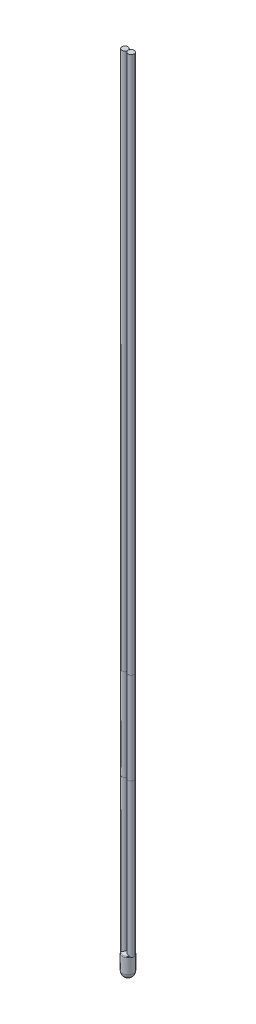
from build123d import *

# Parameters (mm, degrees)
REDONDEO1_R               = 0.2
CROQUIS2_R                = 0.5
SALIENTE_EXTRUIR1_DEPTH   = 25
SALIENTE_EXTRUIR6_START   = -25
CROQUIS2_3_R              = 0.5
SALIENTE_EXTRUIR6_DEPTH   = 15
SALIENTE_EXTRUIR6_2_DEPTH = 15
SALIENTE_EXTRUIR7_START   = -40
CROQUIS2_4_R              = 0.5
SALIENTE_EXTRUIR7_DEPTH   = 88
SALIENTE_EXTRUIR7_2_DEPTH = 88


with BuildPart() as part:
    # Croquis1 → Revolución2 (revolve)
    with BuildSketch(Plane.XY):
        with BuildLine():
            Line((0, 0), (0, 2.5))
            ThreePointArc((0, 2.5), (0.411039098, 2.782931151), (0.9, 2.882532421))
            Line((0.9, 2.882532421), (0.9, -0.9))
            ThreePointArc((0.9, -0.9), (0.263603897, -0.636396103), (0, 0))
        make_face()
    revolve(axis=Axis((0.9, 2.882532421, 0), (0, -1, 0)))

    # Redondeo1
    redondeo1_edges = [part.edges().sort_by_distance(p)[0] for p in [
        (1.8, 2.5, 0),
    ]]
    fillet(redondeo1_edges, radius=REDONDEO1_R)

    # Croquis2 → Saliente-Extruir1 (add)
    with BuildSketch(Plane(origin=(0, 2.415156213, 0), x_dir=(-1, 0, 0), z_dir=(0, -1, 0))):
        with Locations((-1.41, 0)):
            Circle(CROQUIS2_R)
        with Locations((-0.4, 0)):
            Circle(CROQUIS2_R)
    extrude(amount=-SALIENTE_EXTRUIR1_DEPTH)


with BuildPart() as body_2:
    # Croquis2_3 → Saliente-Extruir6 (new body)
    with BuildSketch(Plane(origin=(0, 2.415156213, 0), x_dir=(-1, 0, 0), z_dir=(0, -1, 0)).offset(SALIENTE_EXTRUIR6_START)):
        with Locations((-1.41, 0)):
            Circle(CROQUIS2_3_R)
    extrude(amount=-SALIENTE_EXTRUIR6_DEPTH)


with BuildPart() as body_3:
    # Croquis2_3 → Saliente-Extruir6 2 (new body)
    with BuildSketch(Plane(origin=(0, 2.415156213, 0), x_dir=(-1, 0, 0), z_dir=(0, -1, 0)).offset(SALIENTE_EXTRUIR6_START)):
        with Locations((-0.4, 0)):
            Circle(CROQUIS2_3_R)
    extrude(amount=-SALIENTE_EXTRUIR6_2_DEPTH)


with BuildPart() as body_4:
    # Croquis2_4 → Saliente-Extruir7 (new body)
    with BuildSketch(Plane(origin=(0, 2.415156213, 0), x_dir=(-1, 0, 0), z_dir=(0, -1, 0)).offset(SALIENTE_EXTRUIR7_START)):
        with Locations((-1.41, 0)):
            Circle(CROQUIS2_4_R)
    extrude(amount=-SALIENTE_EXTRUIR7_DEPTH)


with BuildPart() as body_5:
    # Croquis2_4 → Saliente-Extruir7 2 (new body)
    with BuildSketch(Plane(origin=(0, 2.415156213, 0), x_dir=(-1, 0, 0), z_dir=(0, -1, 0)).offset(SALIENTE_EXTRUIR7_START)):
        with Locations((-0.4, 0)):
            Circle(CROQUIS2_4_R)
    extrude(amount=-SALIENTE_EXTRUIR7_2_DEPTH)


solid = Compound([part.part, body_2.part, body_3.part, body_4.part, body_5.part])
